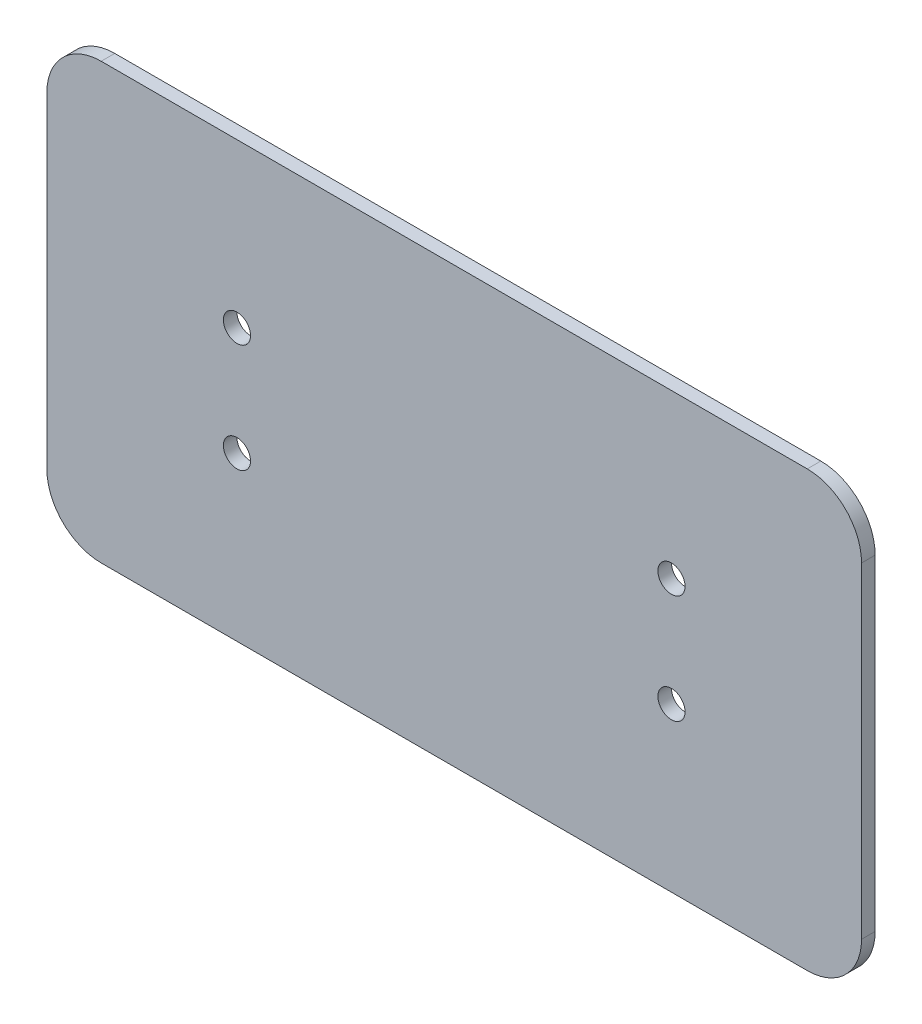
from build123d import *

# Parameters (mm, degrees)
SKETCH1_R           = 3.175
BOSS_EXTRUDE1_DEPTH = 3.175


with BuildPart() as part:
    # Sketch1 → Boss-Extrude1 (new body)
    with BuildSketch(Plane.XY):
        with BuildLine():
            Line((296.179280684, -204.758683659), (461.279280684, -204.758683659))
            ThreePointArc((461.279280684, -204.758683659), (470.259536805, -208.478427538), (473.979280684, -217.458683659))
            Line((473.979280684, -217.458683659), (473.979280684, -293.658683659))
            ThreePointArc((473.979280684, -293.658683659), (470.259536805, -302.63893978), (461.279280684, -306.358683659))
            Line((461.279280684, -306.358683659), (296.179280684, -306.358683659))
            ThreePointArc((296.179280684, -306.358683659), (287.199024563, -302.63893978), (283.479280684, -293.658683659))
            Line((283.479280684, -293.658683659), (283.479280684, -217.458683659))
            ThreePointArc((283.479280684, -217.458683659), (287.199024563, -208.478427538), (296.179280684, -204.758683659))
        make_face()
        with Locations((429.529280684, -268.258683659)):
            Circle(SKETCH1_R, mode=Mode.SUBTRACT)
        with Locations((429.529280684, -242.858683659)):
            Circle(SKETCH1_R, mode=Mode.SUBTRACT)
        with Locations((327.929280684, -242.858683659)):
            Circle(SKETCH1_R, mode=Mode.SUBTRACT)
        with Locations((327.929280684, -268.258683659)):
            Circle(SKETCH1_R, mode=Mode.SUBTRACT)
    extrude(amount=BOSS_EXTRUDE1_DEPTH)


solid = part.part
